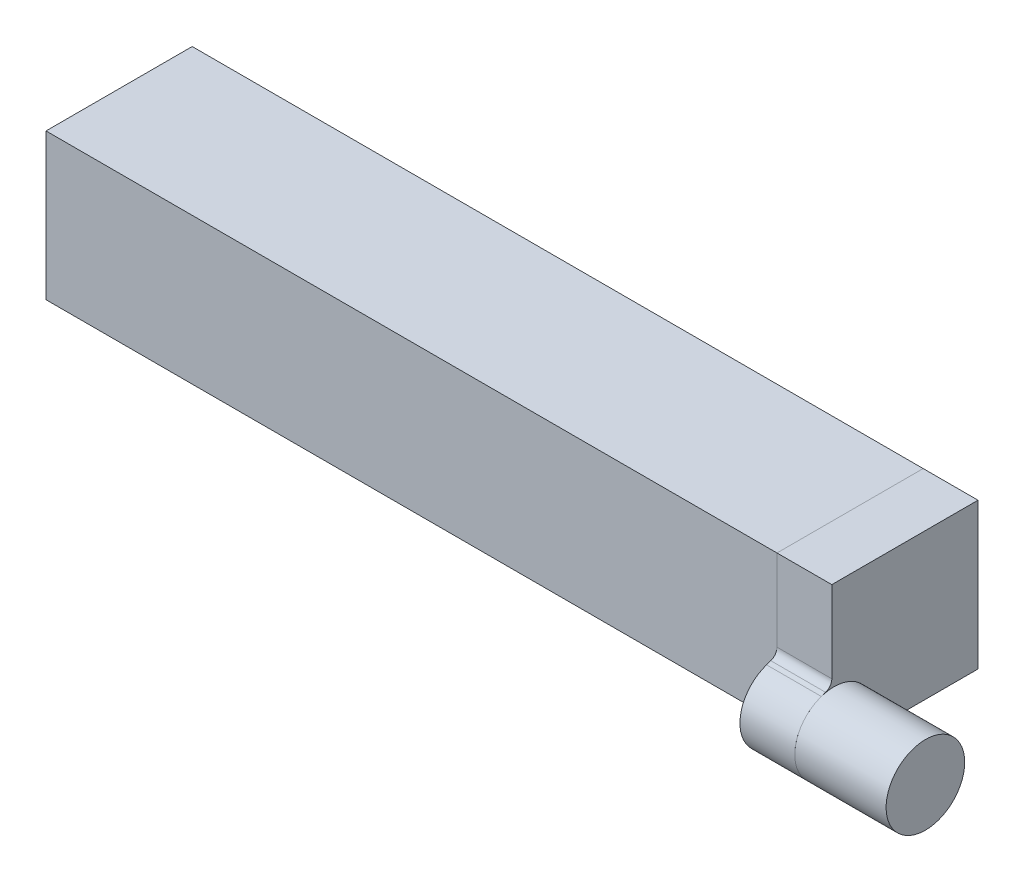
from build123d import *

# Parameters (mm, degrees)
SKETCH2_W           = 8
SKETCH2_H           = 8
SKETCH2_W_2         = 4.8
SKETCH2_H_2         = 4.8
BOSS_EXTRUDE1_DEPTH = 10
BOSS_EXTRUDE2_START = 15
SKETCH2_2_W         = 8
SKETCH2_2_H         = 8
BOSS_EXTRUDE2_DEPTH = 25
BOSS_EXTRUDE3_DEPTH = 3
SKETCH6_R           = 2.15
BOSS_EXTRUDE4_DEPTH = 5
BOSS_EXTRUDE5_START = 10
SKETCH2_4_W         = 8
SKETCH2_4_H         = 8
SKETCH2_4_W_2       = 4.8
SKETCH2_4_H_2       = 4.8
BOSS_EXTRUDE5_DEPTH = 5
FILLET1_R           = 0.5
FILLET2_R           = 0.5


with BuildPart() as part:
    # Sketch2 → Boss-Extrude1 (new body)
    with BuildSketch(Plane(origin=(0, 0, 0), x_dir=(0, 0, -1), z_dir=(1, 0, 0))):
        Rectangle(SKETCH2_W, SKETCH2_H)
        Rectangle(SKETCH2_W_2, SKETCH2_H_2, mode=Mode.SUBTRACT)
    extrude(amount=BOSS_EXTRUDE1_DEPTH)



with BuildPart() as body_2:
    # Sketch2_2 → Boss-Extrude2 (new body)
    with BuildSketch(Plane(origin=(0, 0, 0), x_dir=(0, 0, -1), z_dir=(1, 0, 0)).offset(BOSS_EXTRUDE2_START)):
        Rectangle(SKETCH2_2_W, SKETCH2_2_H)
    extrude(amount=BOSS_EXTRUDE2_DEPTH)


with BuildPart() as body_3:
    # Sketch5 → Boss-Extrude3 (new body)
    with BuildSketch(Plane(origin=(40, 0, 0), x_dir=(0, 0, -1), z_dir=(1, 0, 0))):
        with BuildLine():
            Line((-4, 4), (4, 4))
            Line((4, 4), (4, -4))
            Line((4, -4), (0, -4))
            Line((0, -4), (-3.183580068, -5.085658744))
            ThreePointArc((-3.183580068, -5.085658744), (-5.912457005, -3.744677514), (-4.571475775, -1.015800576))
            Line((-4.571475775, -1.015800576), (-4, -0.820916936))
            Line((-4, -0.820916936), (-4, 4))
        make_face()
    extrude(amount=BOSS_EXTRUDE3_DEPTH)

    # Fillet2
    fillet2_edges = [body_3.edges().sort_by_distance(p)[0] for p in [
        (41.5, -0.820916936, 4),
    ]]
    fillet(fillet2_edges, radius=FILLET2_R)


with BuildPart() as body_4:
    # Sketch6 → Boss-Extrude4 (new body)
    with BuildSketch(Plane(origin=(43, 0, 0), x_dir=(0, 0, -1), z_dir=(1, 0, 0))):
        with Locations((-3.877527921, -3.05072966)):
            Circle(SKETCH6_R)
    extrude(amount=BOSS_EXTRUDE4_DEPTH)


with BuildPart() as part_1:
    add(part.part)

    add(body_2.part)  # Boss-Extrude5 merges body 2
    # Sketch2_4 → Boss-Extrude5 (add)
    with BuildSketch(Plane(origin=(0, 0, 0), x_dir=(0, 0, -1), z_dir=(1, 0, 0)).offset(BOSS_EXTRUDE5_START)):
        Rectangle(SKETCH2_4_W, SKETCH2_4_H)
        Rectangle(SKETCH2_4_W_2, SKETCH2_4_H_2, mode=Mode.SUBTRACT)
    extrude(amount=BOSS_EXTRUDE5_DEPTH)

    # Fillet1
    fillet1_edges = [part_1.edges().sort_by_distance(p)[0] for p in [
        (0, -2.4, 0),
        (0, 0, -2.4),
        (0, 0, 2.4),
        (0, 2.4, 0),
    ]]
    fillet(fillet1_edges, radius=FILLET1_R)


solid = Compound([body_3.part, body_4.part, part_1.part])
